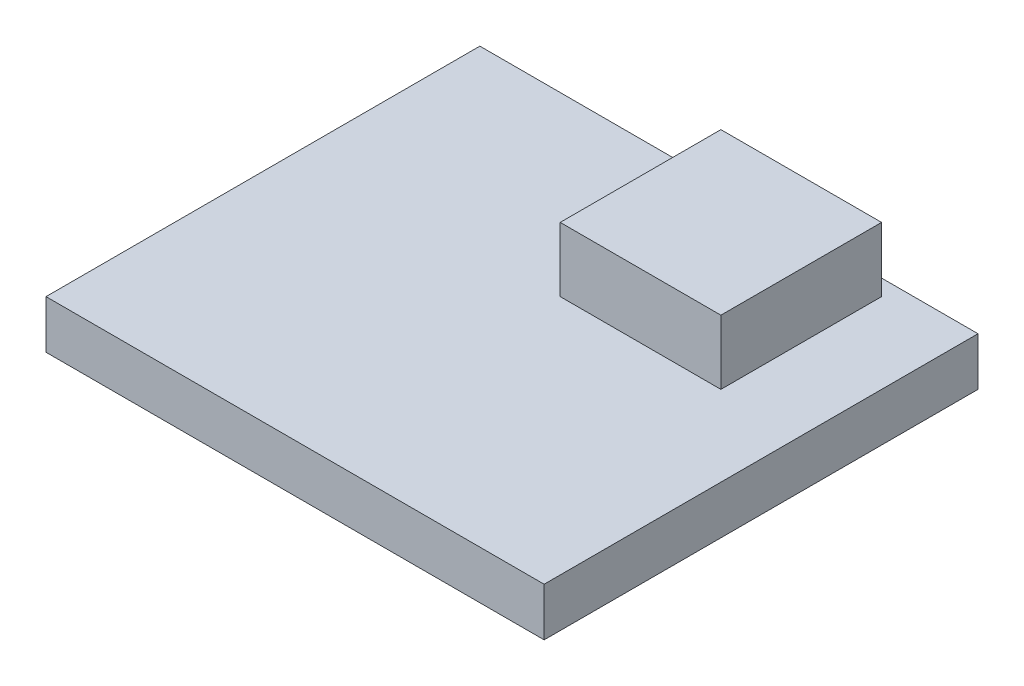
from build123d import *

# Parameters (mm, degrees)
SKETCH1_W           = 31
SKETCH1_H           = 27
BOSS_EXTRUDE1_DEPTH = 3
SKETCH2_W           = 10
SKETCH2_H           = 10
BOSS_EXTRUDE2_DEPTH = 4


with BuildPart() as part:
    # Sketch1 → Boss-Extrude1 (new body)
    with BuildSketch(Plane(origin=(0, 0, 0), x_dir=(1, 0, 0), z_dir=(0, 1, 0))):
        with Locations((0, -1.768348624)):
            Rectangle(SKETCH1_W, SKETCH1_H)
    extrude(amount=BOSS_EXTRUDE1_DEPTH)

    # Sketch2 → Boss-Extrude2 (add)
    with BuildSketch(Plane(origin=(0, 3, 0), x_dir=(1, 0, 0), z_dir=(0, 1, 0))):
        with Locations((5.5, 5.731651376)):
            Rectangle(SKETCH2_W, SKETCH2_H)
    extrude(amount=BOSS_EXTRUDE2_DEPTH)


solid = part.part
